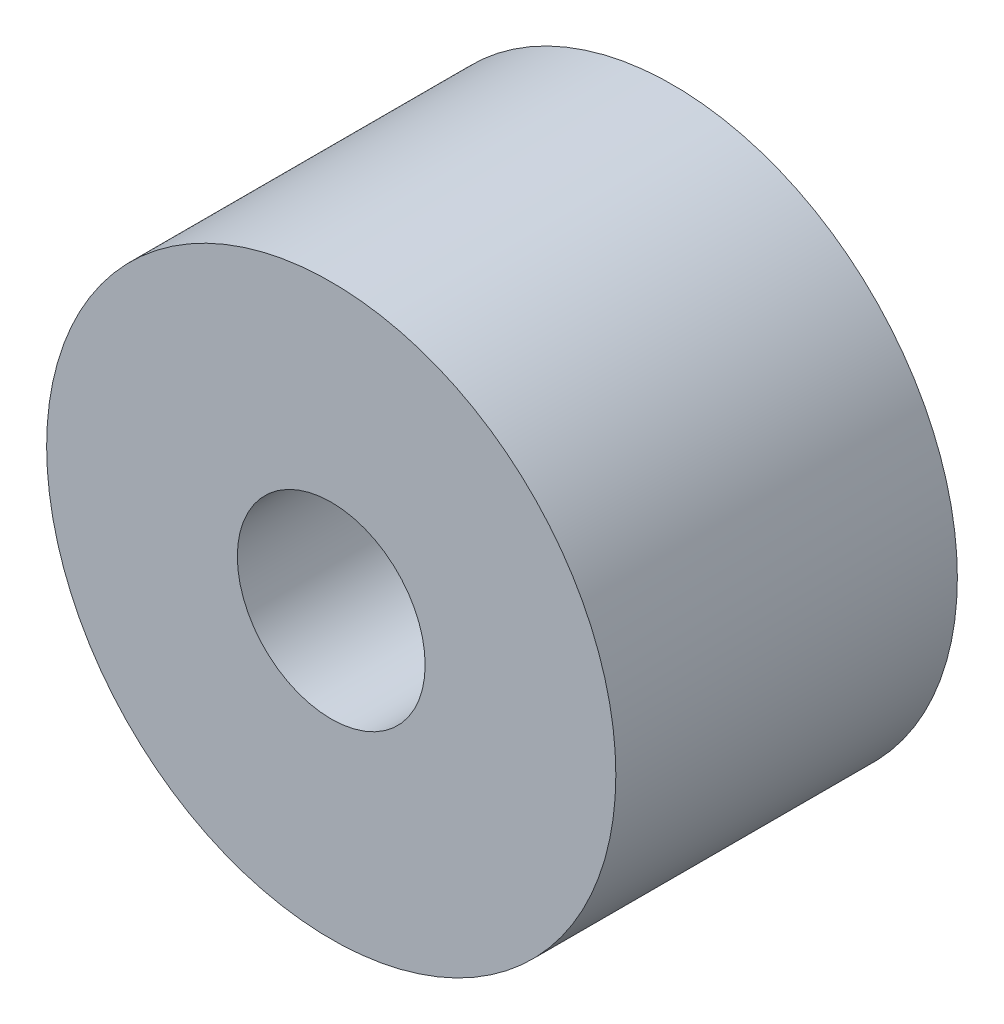
from build123d import *

# Parameters (mm, degrees)
SKETCH_1_R          = 1.65
EXTRUDE_1_DEPTH     = 3
FILLET_1_R          = 4
FILLET_2_R          = 2
SKETCH_2_R          = 32.383706152
SKETCH_2_R_2        = 5
CUT_EXTRUDE_1_DEPTH = 10


with BuildPart() as part:
    # ｽｹｯﾁ1 → ﾎﾞｽ - 押し出し1 (new, symmetric)
    with BuildSketch(Plane.XY):
        Polygon((103.035796932, 67.586451292), (103.035796932, 78.476037139), (111.915158488, 78.476037139), (111.915158488, 67.586451292), (122.804744336, 67.586451292), (122.804744336, 58.707089735), (111.915158488, 58.707089735), (111.915158488, 47.817503888), (103.035796932, 47.817503888), (103.035796932, 58.707089735), (92.146211085, 58.707089735), (92.146211085, 67.586451292), align=None)
        with Locations((107.47547771, 63.146770513)):
            Circle(SKETCH_1_R, mode=Mode.SUBTRACT)
    extrude(amount=EXTRUDE_1_DEPTH, both=True)

    # ﾌｨﾚｯﾄ1
    fillet_1_edges = [part.edges().sort_by_distance(p)[0] for p in [
        (122.804744336, 67.586451292, 0),
        (111.915158488, 47.817503888, 0),
        (92.146211085, 58.707089735, 0),
        (103.035796932, 78.476037139, 0),
    ]]
    fillet(fillet_1_edges, radius=FILLET_1_R)

    # ﾌｨﾚｯﾄ2
    fillet_2_edges = [part.edges().sort_by_distance(p)[0] for p in [
        (111.915158488, 67.586451292, 0),
        (111.915158488, 58.707089735, 0),
        (103.035796932, 58.707089735, 0),
        (103.035796932, 67.586451292, 0),
    ]]
    fillet(fillet_2_edges, radius=FILLET_2_R)

    # ｽｹｯﾁ2 → ｶｯﾄ - 押し出し1 (cut)
    with BuildSketch(Plane.XY.offset(3)):
        with Locations((107.47547771, 63.146770513)):
            Circle(SKETCH_2_R)
        with BuildLine():
            Line((103.035796932, 47.817503888), (107.915158488, 47.817503888))
            ThreePointArc((107.915158488, 47.817503888), (110.743585613, 48.989076763), (111.915158488, 51.817503888))
            Line((111.915158488, 51.817503888), (111.915158488, 56.707089735))
            ThreePointArc((111.915158488, 56.707089735), (112.500944926, 58.121303298), (113.915158488, 58.707089735))
            Line((113.915158488, 58.707089735), (122.804744336, 58.707089735))
            Line((122.804744336, 58.707089735), (122.804744336, 63.586451292))
            ThreePointArc((122.804744336, 63.586451292), (121.63317146, 66.414878416), (118.804744336, 67.586451292))
            Line((118.804744336, 67.586451292), (113.915158488, 67.586451292))
            ThreePointArc((113.915158488, 67.586451292), (112.500944926, 68.172237729), (111.915158488, 69.586451292))
            Line((111.915158488, 69.586451292), (111.915158488, 78.476037139))
            Line((111.915158488, 78.476037139), (107.035796932, 78.476037139))
            ThreePointArc((107.035796932, 78.476037139), (104.207369807, 77.304464263), (103.035796932, 74.476037139))
            Line((103.035796932, 74.476037139), (103.035796932, 69.586451292))
            ThreePointArc((103.035796932, 69.586451292), (102.450010495, 68.172237729), (101.035796932, 67.586451292))
            Line((101.035796932, 67.586451292), (92.146211085, 67.586451292))
            Line((92.146211085, 67.586451292), (92.146211085, 62.707089735))
            ThreePointArc((92.146211085, 62.707089735), (93.31778396, 59.87866261), (96.146211085, 58.707089735))
            Line((96.146211085, 58.707089735), (101.035796932, 58.707089735))
            ThreePointArc((101.035796932, 58.707089735), (102.450010495, 58.121303298), (103.035796932, 56.707089735))
            Line((103.035796932, 56.707089735), (103.035796932, 47.817503888))
        make_face(mode=Mode.SUBTRACT)
        with BuildLine():
            Line((103.035796932, 56.707089735), (103.035796932, 47.817503888))
            Line((103.035796932, 47.817503888), (107.915158488, 47.817503888))
            ThreePointArc((107.915158488, 47.817503888), (110.743585613, 48.989076763), (111.915158488, 51.817503888))
            Line((111.915158488, 51.817503888), (111.915158488, 56.707089735))
            ThreePointArc((111.915158488, 56.707089735), (112.500944926, 58.121303298), (113.915158488, 58.707089735))
            Line((113.915158488, 58.707089735), (122.804744336, 58.707089735))
            Line((122.804744336, 58.707089735), (122.804744336, 63.586451292))
            ThreePointArc((122.804744336, 63.586451292), (121.63317146, 66.414878416), (118.804744336, 67.586451292))
            Line((118.804744336, 67.586451292), (113.915158488, 67.586451292))
            ThreePointArc((113.915158488, 67.586451292), (112.500944926, 68.172237729), (111.915158488, 69.586451292))
            Line((111.915158488, 69.586451292), (111.915158488, 78.476037139))
            Line((111.915158488, 78.476037139), (107.035796932, 78.476037139))
            ThreePointArc((107.035796932, 78.476037139), (104.207369807, 77.304464263), (103.035796932, 74.476037139))
            Line((103.035796932, 74.476037139), (103.035796932, 69.586451292))
            ThreePointArc((103.035796932, 69.586451292), (102.450010495, 68.172237729), (101.035796932, 67.586451292))
            Line((101.035796932, 67.586451292), (92.146211085, 67.586451292))
            Line((92.146211085, 67.586451292), (92.146211085, 62.707089735))
            ThreePointArc((92.146211085, 62.707089735), (93.31778396, 59.87866261), (96.146211085, 58.707089735))
            Line((96.146211085, 58.707089735), (101.035796932, 58.707089735))
            ThreePointArc((101.035796932, 58.707089735), (102.450010495, 58.121303298), (103.035796932, 56.707089735))
        make_face()
        with Locations((107.47547771, 63.146770513)):
            Circle(SKETCH_2_R_2, mode=Mode.SUBTRACT)
    extrude(amount=-CUT_EXTRUDE_1_DEPTH, mode=Mode.SUBTRACT)


solid = part.part
